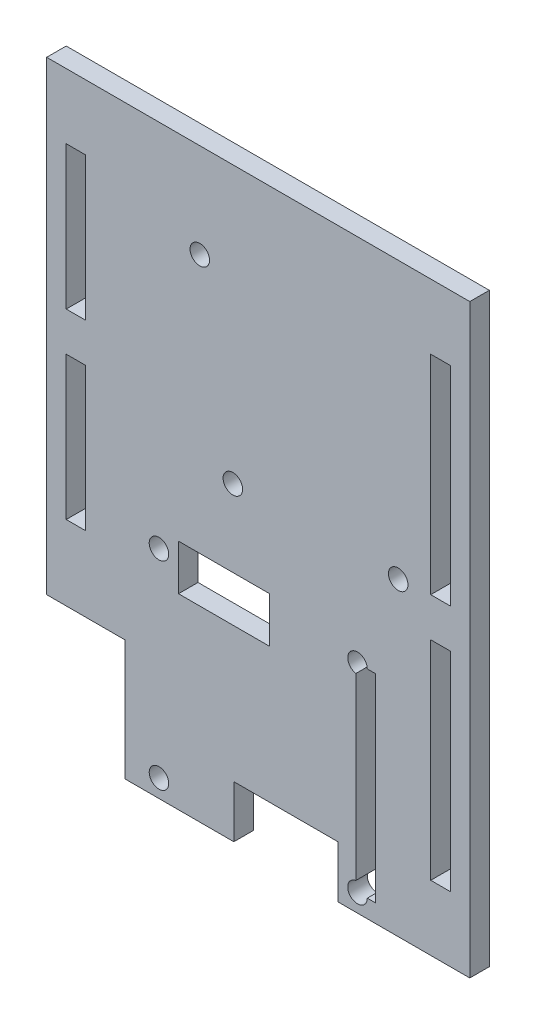
from build123d import *

# Parameters (mm, degrees)
SKETCH1_W           = 65
SKETCH1_H           = 90
BOSS_EXTRUDE1_DEPTH = 3
SKETCH3_R           = 1.5
CUT_EXTRUDE2_DEPTH  = 3
SKETCH4_R           = 1.5
CUT_EXTRUDE3_DEPTH  = 4
SKETCH5_W           = 3
SKETCH5_H           = 32
CUT_EXTRUDE4_DEPTH  = 4
SKETCH6_W           = 3
SKETCH6_H           = 22
CUT_EXTRUDE5_DEPTH  = 4
SKETCH7_W           = 3
SKETCH7_H           = 30.5
SKETCH7_W_2         = 14
SKETCH7_H_2         = 7
SKETCH7_W_3         = 16
SKETCH7_H_3         = 8
CUT_EXTRUDE6_DEPTH  = 4
SKETCH8_W           = 12
SKETCH8_H           = 18.5
CUT_EXTRUDE7_DEPTH  = 4


with BuildPart() as part:
    # Sketch1 → Boss-Extrude1 (new body)
    with BuildSketch(Plane.XY):
        Rectangle(SKETCH1_W, SKETCH1_H)
    extrude(amount=-BOSS_EXTRUDE1_DEPTH)

    # Sketch3 → Cut-Extrude2 (cut)
    with BuildSketch(Plane.XY):
        with Locations((-8.98, 30.5)):
            Circle(SKETCH3_R)
        with Locations((-3.9, 2.56)):
            Circle(SKETCH3_R)
        with Locations((21.5, 2.56)):
            Circle(SKETCH3_R)
    extrude(amount=-CUT_EXTRUDE2_DEPTH, mode=Mode.SUBTRACT)

    # Sketch4 → Cut-Extrude3 (cut, through all)
    with BuildSketch(Plane.XY):
        with Locations((-15.25, -42.25)):
            Circle(SKETCH4_R)
        with Locations((-15.25, -11.75)):
            Circle(SKETCH4_R)
        with Locations((15.25, -42.25)):
            Circle(SKETCH4_R)
        with Locations((15.25, -11.75)):
            Circle(SKETCH4_R)
    extrude(amount=-CUT_EXTRUDE3_DEPTH, mode=Mode.SUBTRACT)

    # Sketch5 → Cut-Extrude4 (cut, through all)
    with BuildSketch(Plane.XY):
        with Locations((28, -19)):
            Rectangle(SKETCH5_W, SKETCH5_H)
        with Locations((28, 19)):
            Rectangle(SKETCH5_W, SKETCH5_H)
    extrude(amount=-CUT_EXTRUDE4_DEPTH, mode=Mode.SUBTRACT)

    # Sketch6 → Cut-Extrude5 (cut, through all)
    with BuildSketch(Plane.XY):
        with Locations((-28, -4)):
            Rectangle(SKETCH6_W, SKETCH6_H)
        with Locations((-28, 24)):
            Rectangle(SKETCH6_W, SKETCH6_H)
    extrude(amount=-CUT_EXTRUDE5_DEPTH, mode=Mode.SUBTRACT)

    # Sketch7 → Cut-Extrude6 (cut, through all)
    with BuildSketch(Plane.XY):
        with Locations((16.5, -27)):
            Rectangle(SKETCH7_W, SKETCH7_H)
        with Locations((-5.25, -12.75)):
            Rectangle(SKETCH7_W_2, SKETCH7_H_2)
        with Locations((4.25, -41)):
            Rectangle(SKETCH7_W_3, SKETCH7_H_3)
    extrude(amount=-CUT_EXTRUDE6_DEPTH, mode=Mode.SUBTRACT)

    # Sketch8 → Cut-Extrude7 (cut, through all)
    with BuildSketch(Plane.XY):
        with Locations((-26.5, -35.75)):
            Rectangle(SKETCH8_W, SKETCH8_H)
    extrude(amount=-CUT_EXTRUDE7_DEPTH, mode=Mode.SUBTRACT)


solid = part.part
